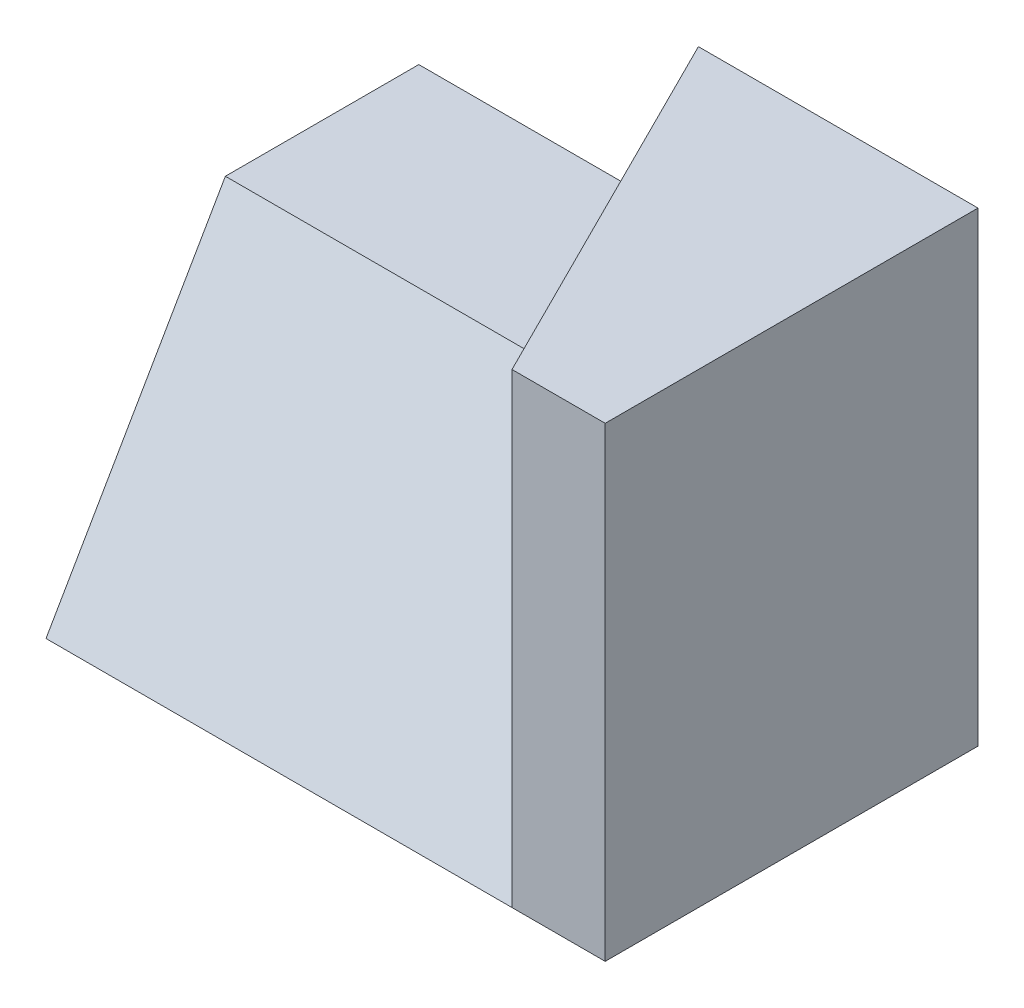
from build123d import *

# Parameters (mm, degrees)
SKETCH1_W      = 90
SKETCH1_H      = 60
EXTRUDE1_DEPTH = 50
EXTRUDE2_DEPTH = 91
EXTRUDE3_DEPTH = 75


with BuildPart() as part:
    # Sketch1 → Extrude1 (new body)
    with BuildSketch(Plane(origin=(0, 0, 0), x_dir=(1, 0, 0), z_dir=(0, 1, 0))):
        with Locations((45, 30)):
            Rectangle(SKETCH1_W, SKETCH1_H)
    extrude(amount=EXTRUDE1_DEPTH)

    # Sketch2 → Extrude2 (cut, through all)
    with BuildSketch(Plane(origin=(90, 0, 0), x_dir=(0, 0, -1), z_dir=(1, 0, 0))):
        Polygon((0, 0), (28.867513459, 50), (0, 50), align=None)
    extrude(amount=-EXTRUDE2_DEPTH, mode=Mode.SUBTRACT)

    # Sketch3 → Extrude3 (add)
    with BuildSketch(Plane(origin=(0, 0, 0), x_dir=(1, 0, 0), z_dir=(0, 1, 0))):
        Polygon((90, 60), (90, 0), (75, 0), (45, 60), align=None)
    extrude(amount=EXTRUDE3_DEPTH)


solid = part.part
